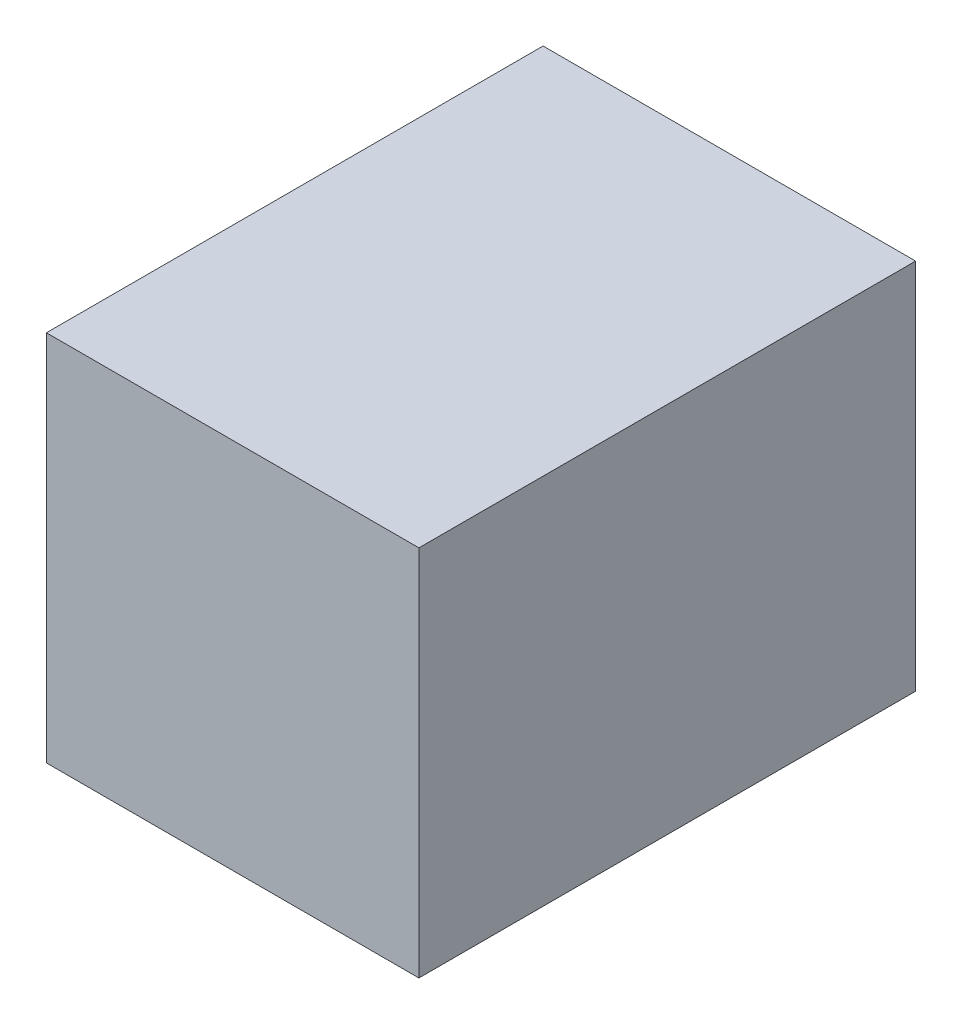
from build123d import *

# Parameters (mm, degrees)
SKETCH1_W           = 6
SKETCH1_H           = 6
BOSS_EXTRUDE1_DEPTH = 8


with BuildPart() as part:
    # Sketch1 → Boss-Extrude1 (new body)
    with BuildSketch(Plane.XY):
        Rectangle(SKETCH1_W, SKETCH1_H)
    extrude(amount=BOSS_EXTRUDE1_DEPTH)


solid = part.part
